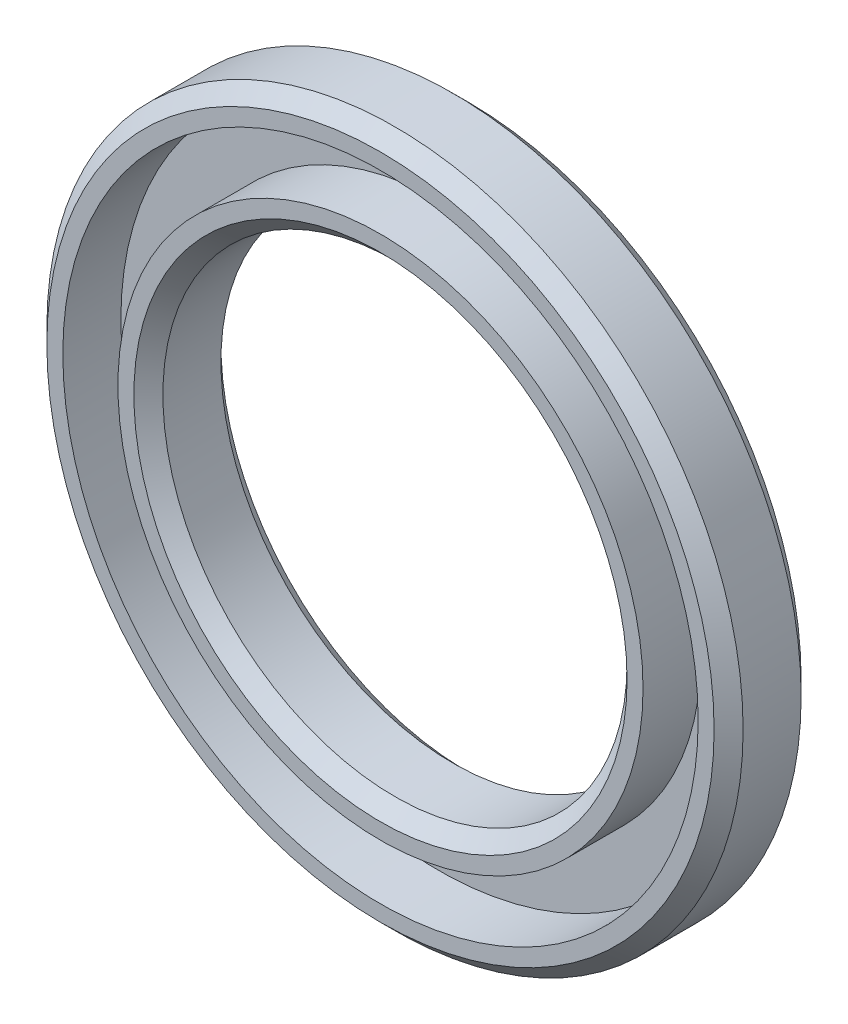
from build123d import *

# Parameters (mm, degrees)
SKETCH1_R           = 12
SKETCH1_R_2         = 8
BOSS_EXTRUDE1_DEPTH = 3
CHAMFER1_SIZE       = 0.5
SKETCH2_R           = 10.95
SKETCH2_R_2         = 9.05
CUT_EXTRUDE1_DEPTH  = 2


with BuildPart() as part:
    # Sketch1 → Boss-Extrude1 (new body)
    with BuildSketch(Plane.XY):
        Circle(SKETCH1_R)
        Circle(SKETCH1_R_2, mode=Mode.SUBTRACT)
    extrude(amount=BOSS_EXTRUDE1_DEPTH)

    # Chamfer1
    chamfer1_edges = [part.edges().sort_by_distance(p)[0] for p in [
        (-12, 0, 0),
        (-12, 0, 3),
        (-8, 0, 0),
        (-8, 0, 3),
    ]]
    chamfer(chamfer1_edges, length=CHAMFER1_SIZE)

    # Sketch2 → Cut-Extrude1 (cut)
    with BuildSketch(Plane.XY.offset(3)):
        Circle(SKETCH2_R)
        Circle(SKETCH2_R_2, mode=Mode.SUBTRACT)
    extrude(amount=-CUT_EXTRUDE1_DEPTH, mode=Mode.SUBTRACT)


solid = part.part
